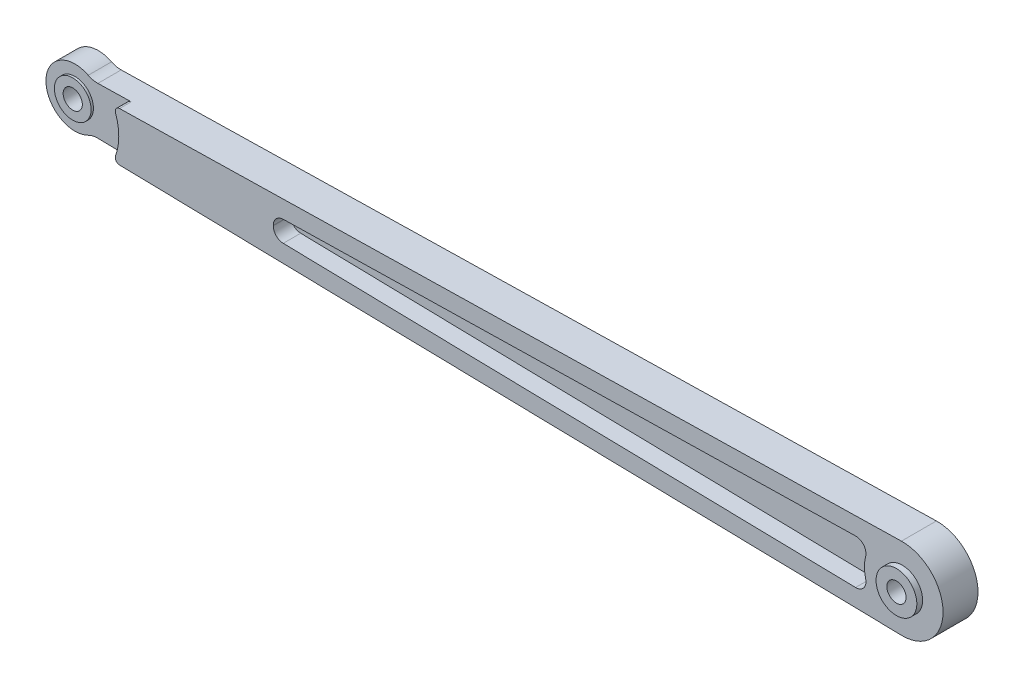
from build123d import *

# Parameters (mm, degrees)
SKETCH1_R           = 1.65
BOSS_EXTRUDE1_DEPTH = 6
SKETCH2_R           = 3.5
BOSS_EXTRUDE2_DEPTH = 1
SKETCH4_R           = 1.65
CUT_EXTRUDE1_DEPTH  = 12
SKETCH7_R           = 9.5
CUT_EXTRUDE3_DEPTH  = 2
FILLET2_R           = 0.75
FILLET3_R           = 3.5
SKETCH8_R           = 3.15
SKETCH8_R_2         = 1.65
BOSS_EXTRUDE5_DEPTH = 0.4
CUT_EXTRUDE4_DEPTH  = 3


with BuildPart() as part:
    # Sketch1 → Boss-Extrude1 (new body)
    with BuildSketch(Plane.XY):
        with BuildLine():
            ThreePointArc((-0.145833333, -6.998480738), (7, 0), (-0.145833333, 6.998480738))
            Line((-0.145833333, 6.998480738), (-141.083984446, 4.06163185))
            ThreePointArc((-141.083984446, 4.06163185), (-149, 0), (-141.083984446, -4.06163185))
            Line((-141.083984446, -4.06163185), (-0.145833333, -6.998480738))
        make_face()
        with Locations((-144, 0)):
            Circle(SKETCH1_R, mode=Mode.SUBTRACT)
    extrude(amount=BOSS_EXTRUDE1_DEPTH)

    # Sketch2 → Boss-Extrude2 (add)
    with BuildSketch(Plane.XY.offset(6)):
        Circle(SKETCH2_R)
    extrude(amount=BOSS_EXTRUDE2_DEPTH)

    # Sketch4 → Cut-Extrude1 (cut)
    with BuildSketch(Plane.XY.offset(7)):
        Circle(SKETCH4_R)
    extrude(amount=-CUT_EXTRUDE1_DEPTH, mode=Mode.SUBTRACT)

    # Sketch7 → Cut-Extrude3 (cut)
    with BuildSketch(Plane.XY.offset(6)):
        with Locations((-144, 0)):
            Circle(SKETCH7_R)
    extrude(amount=-CUT_EXTRUDE3_DEPTH, mode=Mode.SUBTRACT)

    # Fillet2
    fillet2_edges = [part.edges().sort_by_distance(p)[0] for p in [
        (-135.468359541, 4.178649433, 5),
        (-135.468359541, -4.178649433, 5),
    ]]
    fillet(fillet2_edges, radius=FILLET2_R)

    # Fillet3
    fillet3_edges = [part.edges().sort_by_distance(p)[0] for p in [
        (-141.083984446, -4.06163185, 2),
        (-141.083984446, 4.06163185, 2),
    ]]
    fillet(fillet3_edges, radius=FILLET3_R)

    # Sketch8 → Boss-Extrude5 (add)
    with BuildSketch(Plane.XY.offset(4)):
        with Locations((-144, 0)):
            Circle(SKETCH8_R)
        with Locations((-144, 0)):
            Circle(SKETCH8_R_2, mode=Mode.SUBTRACT)
    extrude(amount=BOSS_EXTRUDE5_DEPTH)

    # Sketch9 → Cut-Extrude4 (cut)
    with BuildSketch(Plane.XY.offset(6)):
        with BuildLine():
            Line((-8.018864585, -3.833772393), (-106.262176435, -1.786592415))
            ThreePointArc((-106.262176435, -1.786592415), (-107.476577581, -1.260839283), (-107.975717263, -0.035259389))
            ThreePointArc((-107.975717263, -0.035259389), (-107.975700008, 0), (-107.975717263, 0.035259389))
            ThreePointArc((-107.975717263, 0.035259389), (-107.476577581, 1.260839283), (-106.262176435, 1.786592415))
            Line((-106.262176435, 1.786592415), (-8.018864585, 3.833772393))
            ThreePointArc((-8.018864585, 3.833772393), (-6.60867738, 3.168296566), (-6.289168562, 1.642059316))
            ThreePointArc((-6.289168562, 1.642059316), (-6.5, 0), (-6.289168562, -1.642059316))
            ThreePointArc((-6.289168562, -1.642059316), (-6.60867738, -3.168296566), (-8.018864585, -3.833772393))
        make_face()
    extrude(amount=-CUT_EXTRUDE4_DEPTH, mode=Mode.SUBTRACT)


solid = part.part
